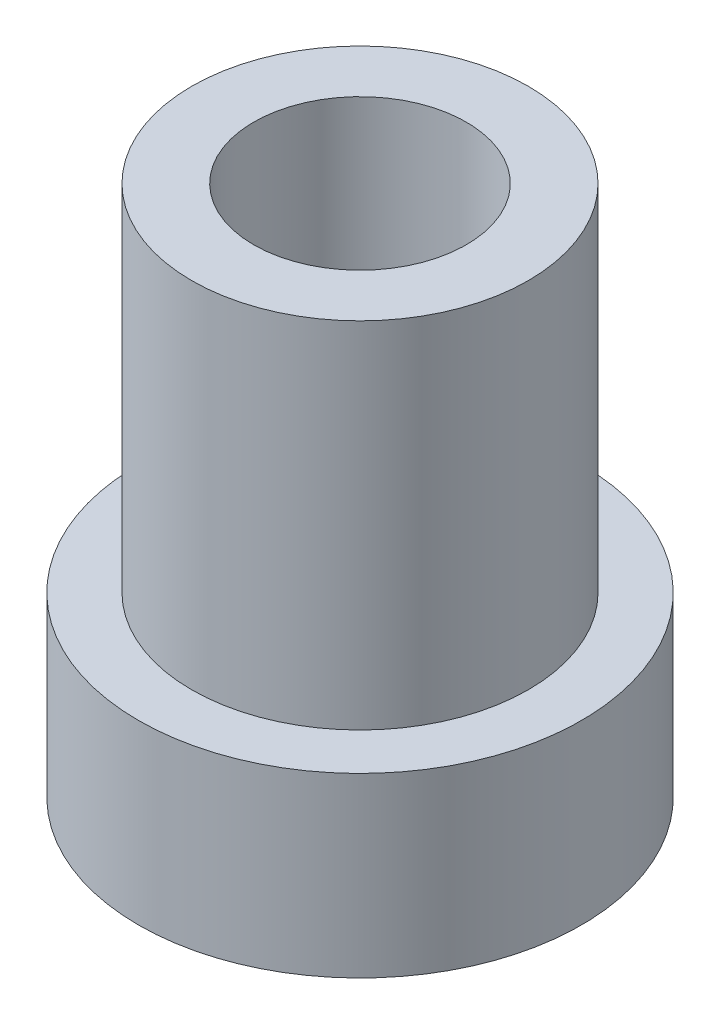
from build123d import *

# Parameters (mm, degrees)
SKETCH1_R                           = 6.25
SKETCH1_R_2                         = 3
EXTRUDE1_DEPTH                      = 2.5
EXTRUDE1_DEPTH_BACK                 = 2.5
SKETCH2_R                           = 4.75
SKETCH2_R_2                         = 3
EXTRUDE2_DEPTH                      = 10
M2X0_4_TAPPED_HOLE1_D               = 1.6
M2X0_4_TAPPED_HOLE1_DEPTH           = 5.2
M2X0_4_TAPPED_HOLE1_TIP             = 0.480688495
M2X0_4_TAPPED_HOLE1_ON_FACE_2_D     = 1.6
M2X0_4_TAPPED_HOLE1_ON_FACE_2_DEPTH = 5.2
M2X0_4_TAPPED_HOLE1_ON_FACE_2_TIP   = 0.480688495


with BuildPart() as part:
    # Sketch1 → Extrude1 (new body, two sides)
    with BuildSketch(Plane(origin=(0, 0, 0), x_dir=(1, 0, 0), z_dir=(0, 1, 0))) as extrude1_sk:
        with Locations(Location((0, 0, 0), (0, 0, 270))):  # turned: the seam where the file's is
            Circle(SKETCH1_R)
        with Locations(Location((0, 0, 0), (0, 0, 270))):  # turned: the seam where the file's is
            Circle(SKETCH1_R_2, mode=Mode.SUBTRACT)
    extrude(amount=EXTRUDE1_DEPTH)
    extrude(extrude1_sk.sketch, amount=-EXTRUDE1_DEPTH_BACK)

    # Sketch2 → Extrude2 (add)
    with BuildSketch(Plane(origin=(0, 2.5, 0), x_dir=(1, 0, 0), z_dir=(0, 1, 0))):
        with Locations(Location((0, 0, 0), (0, 0, 270))):  # turned: the seam where the file's is
            Circle(SKETCH2_R)
        with Locations(Location((0, 0, 0), (0, 0, 270))):  # turned: the seam where the file's is
            Circle(SKETCH2_R_2, mode=Mode.SUBTRACT)
    extrude(amount=EXTRUDE2_DEPTH)

    # M2x0.4 Tapped Hole1
    with Locations(Plane(origin=(0, 0, -6.25), x_dir=(-1, 0, 0), z_dir=(0, 0, -1))):
        with Locations((0, 0)):
            Hole(M2X0_4_TAPPED_HOLE1_D / 2, depth=M2X0_4_TAPPED_HOLE1_DEPTH)
            with Locations((0, 0, -(M2X0_4_TAPPED_HOLE1_DEPTH + M2X0_4_TAPPED_HOLE1_TIP / 2))):  # 118° drill point
                Cone(0, M2X0_4_TAPPED_HOLE1_D / 2, M2X0_4_TAPPED_HOLE1_TIP, mode=Mode.SUBTRACT)

    # M2x0.4 Tapped Hole1 on face 2
    with Locations(Plane(origin=(-6.25, 0, 0), x_dir=(0, 0, -1), z_dir=(-1, 0, 0))):
        with Locations((0, 0)):
            Hole(M2X0_4_TAPPED_HOLE1_ON_FACE_2_D / 2, depth=M2X0_4_TAPPED_HOLE1_ON_FACE_2_DEPTH)
            with Locations((0, 0, -(M2X0_4_TAPPED_HOLE1_ON_FACE_2_DEPTH + M2X0_4_TAPPED_HOLE1_ON_FACE_2_TIP / 2))):  # 118° drill point
                Cone(0, M2X0_4_TAPPED_HOLE1_ON_FACE_2_D / 2, M2X0_4_TAPPED_HOLE1_ON_FACE_2_TIP, mode=Mode.SUBTRACT)


solid = part.part
